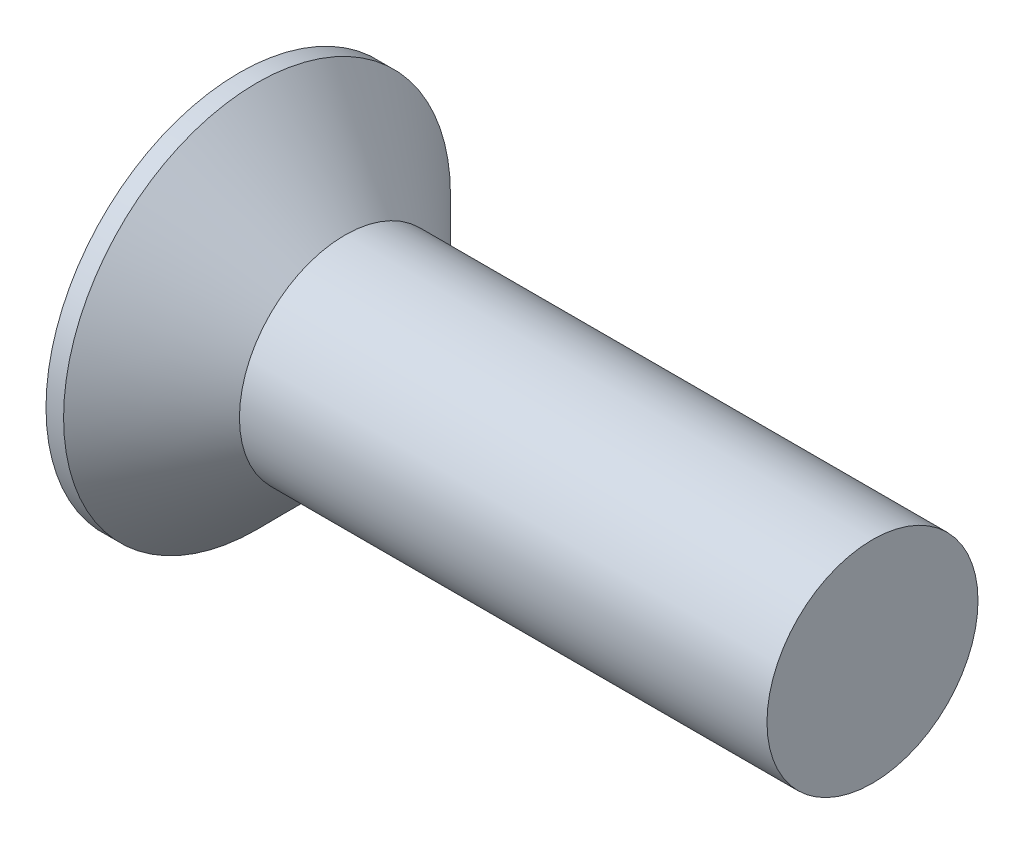
from build123d import *


with BuildPart() as part:
    # Эскиз1 → Повернуть1 (revolve)
    with BuildSketch(Plane.XY):
        Polygon((-3, 0), (-3, 5.5), (-2.5, 5.5), (0, 3), (15, 3), (15, 0), align=None)
    revolve(axis=Axis((-1000, 0, 0), (1, 0, 0)))


solid = part.part
